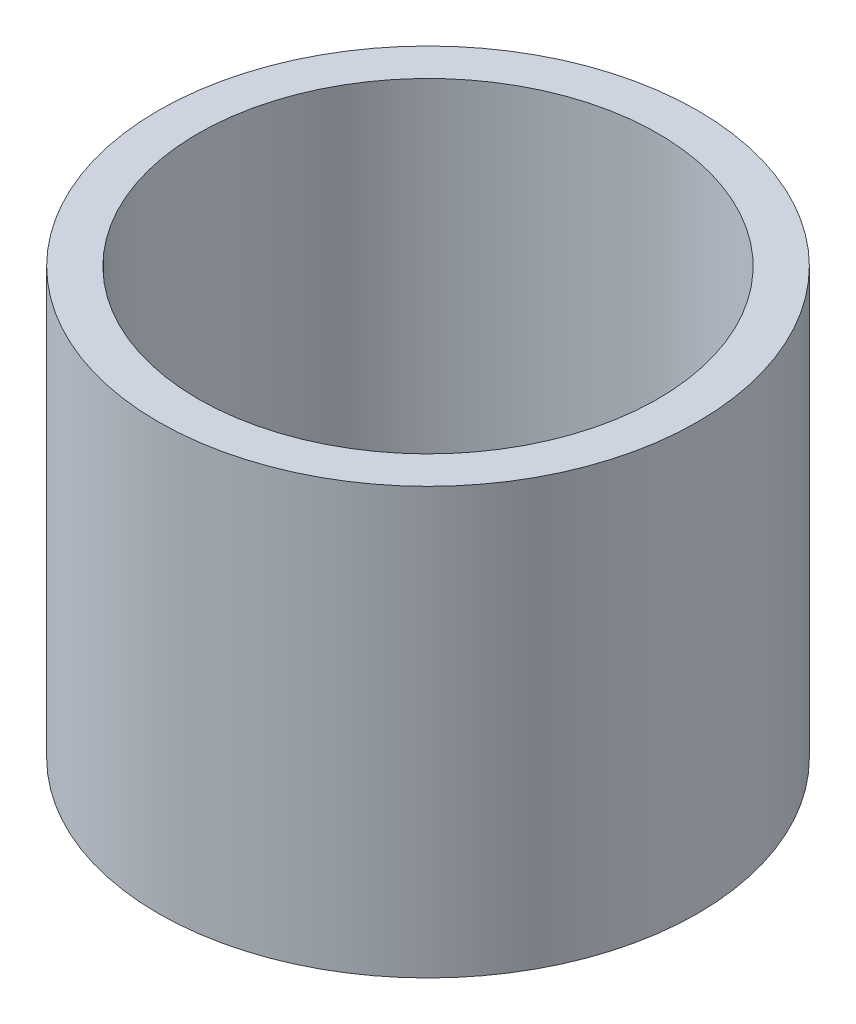
from build123d import *

# Parameters (mm, degrees)
SKETCH1_R      = 9.5
SKETCH1_R_2    = 8.1
EXTRUDE1_DEPTH = 15


with BuildPart() as part:
    # Sketch1 → Extrude1 (new body)
    with BuildSketch(Plane(origin=(0, 0, 0), x_dir=(1, 0, 0), z_dir=(0, 1, 0))):
        Circle(SKETCH1_R)
        Circle(SKETCH1_R_2, mode=Mode.SUBTRACT)
    extrude(amount=EXTRUDE1_DEPTH)


solid = part.part
